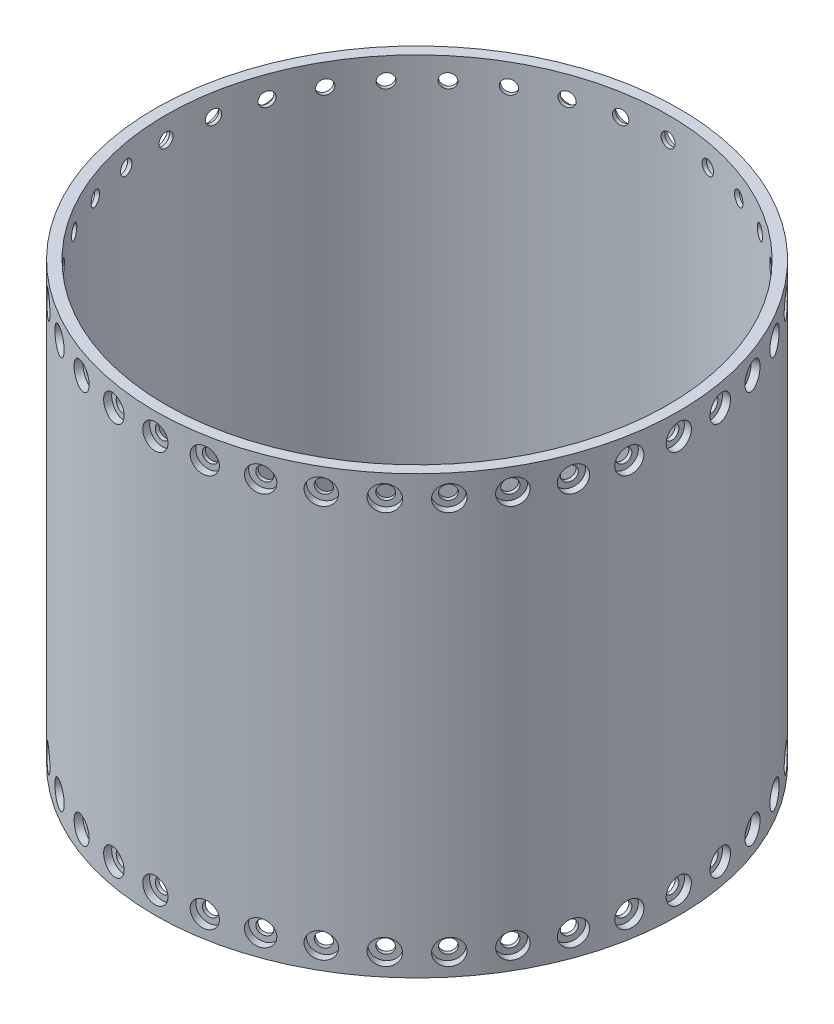
from build123d import *

# Parameters (mm, degrees)
SKETCH1_R           = 152.4
SKETCH1_R_2         = 146.05
BOSS_EXTRUDE1_DEPTH = 254
CIRPATTERN1_COUNT   = 36


with BuildPart() as part:
    # Sketch1 → Boss-Extrude1 (new body)
    with BuildSketch(Plane(origin=(0, 0, 0), x_dir=(1, 0, 0), z_dir=(0, 1, 0))):
        Circle(SKETCH1_R)
        Circle(SKETCH1_R_2, mode=Mode.SUBTRACT)
    extrude(amount=BOSS_EXTRUDE1_DEPTH)

    # Sketch4 → CBORE for 5/16 Button Head Cap Screw1 (revolve, cut)
    with BuildSketch(Plane(origin=(-152.4, 241.3, 0), x_dir=(0, 0, 1), z_dir=(0, 1, 0))):
        Polygon((0, 0), (0, 121.082790345), (4.1021, 118.618), (4.1021, 4.2164), (7.34187, 4.2164), (7.34187, 0), align=None)
    cbore_for_5_16_button_head_cap_screw1 = revolve(axis=Axis((-158.75, 241.3, 0), (1, 0, 0)), mode=Mode.SUBTRACT)

    # CirPattern1: CBORE for 5/16 Button Head Cap Screw1 ×36 about axis
    cirpattern1_axis = Axis((0, 0, 0), (0, 1, 0))
    for i in range(1, CIRPATTERN1_COUNT):
        add(cbore_for_5_16_button_head_cap_screw1.rotate(cirpattern1_axis, i * 360 / CIRPATTERN1_COUNT), mode=Mode.SUBTRACT)

    # Mirror1: CBORE for 5/16 Button Head Cap Screw1 across plane
    add(cbore_for_5_16_button_head_cap_screw1.mirror(Plane.ZX.offset(127)), mode=Mode.SUBTRACT)

    # Mirror1 copy 1 sketch → Mirror1 copy 1 (revolve, cut)
    with BuildSketch(Plane(origin=(-150.084701559, 12.7, 26.463982276), x_dir=(0.173648178, 0, 0.984807753), z_dir=(0, -1, 0))):
        Polygon((0, 0), (0, -121.082790345), (4.1021, -118.618), (4.1021, -4.2164), (7.34187, -4.2164), (7.34187, 0), align=None)
    revolve(axis=Axis((-156.338230791, 12.7, 27.566648205), (-0.984807753, 0, 0.173648178)), mode=Mode.SUBTRACT)

    # Mirror1 copy 2 sketch → Mirror1 copy 2 (revolve, cut)
    with BuildSketch(Plane(origin=(-143.209155408, 12.7, 52.123869843), x_dir=(0.342020143, 0, 0.939692621), z_dir=(0, -1, 0))):
        Polygon((0, 0), (0, -121.082790345), (4.1021, -118.618), (4.1021, -4.2164), (7.34187, -4.2164), (7.34187, 0), align=None)
    revolve(axis=Axis((-149.17620355, 12.7, 54.295697753), (-0.939692621, 0, 0.342020143)), mode=Mode.SUBTRACT)

    # Mirror1 copy 3 sketch → Mirror1 copy 3 (revolve, cut)
    with BuildSketch(Plane(origin=(-131.982271537, 12.7, 76.2), x_dir=(0.5, 0, 0.866025404), z_dir=(0, -1, 0))):
        Polygon((0, 0), (0, -121.082790345), (4.1021, -118.618), (4.1021, -4.2164), (7.34187, -4.2164), (7.34187, 0), align=None)
    revolve(axis=Axis((-137.481532851, 12.7, 79.375), (-0.866025404, 0, 0.5)), mode=Mode.SUBTRACT)

    # Mirror1 copy 4 sketch → Mirror1 copy 4 (revolve, cut)
    with BuildSketch(Plane(origin=(-116.745173131, 12.7, 97.960831716), x_dir=(0.64278761, 0, 0.766044443), z_dir=(0, -1, 0))):
        Polygon((0, 0), (0, -121.082790345), (4.1021, -118.618), (4.1021, -4.2164), (7.34187, -4.2164), (7.34187, 0), align=None)
    revolve(axis=Axis((-121.609555345, 12.7, 102.042533038), (-0.766044443, 0, 0.64278761)), mode=Mode.SUBTRACT)

    # Mirror1 copy 5 sketch → Mirror1 copy 5 (revolve, cut)
    with BuildSketch(Plane(origin=(-97.960831716, 12.7, 116.745173131), x_dir=(0.766044443, 0, 0.64278761), z_dir=(0, -1, 0))):
        Polygon((0, 0), (0, -121.082790345), (4.1021, -118.618), (4.1021, -4.2164), (7.34187, -4.2164), (7.34187, 0), align=None)
    revolve(axis=Axis((-102.042533038, 12.7, 121.609555345), (-0.64278761, 0, 0.766044443)), mode=Mode.SUBTRACT)

    # Mirror1 copy 6 sketch → Mirror1 copy 6 (revolve, cut)
    with BuildSketch(Plane(origin=(-76.2, 12.7, 131.982271537), x_dir=(0.866025404, 0, 0.5), z_dir=(0, -1, 0))):
        Polygon((0, 0), (0, -121.082790345), (4.1021, -118.618), (4.1021, -4.2164), (7.34187, -4.2164), (7.34187, 0), align=None)
    revolve(axis=Axis((-79.375, 12.7, 137.481532851), (-0.5, 0, 0.866025404)), mode=Mode.SUBTRACT)

    # Mirror1 copy 7 sketch → Mirror1 copy 7 (revolve, cut)
    with BuildSketch(Plane(origin=(-52.123869843, 12.7, 143.209155408), x_dir=(0.939692621, 0, 0.342020143), z_dir=(0, -1, 0))):
        Polygon((0, 0), (0, -121.082790345), (4.1021, -118.618), (4.1021, -4.2164), (7.34187, -4.2164), (7.34187, 0), align=None)
    revolve(axis=Axis((-54.295697753, 12.7, 149.17620355), (-0.342020143, 0, 0.939692621)), mode=Mode.SUBTRACT)

    # Mirror1 copy 8 sketch → Mirror1 copy 8 (revolve, cut)
    with BuildSketch(Plane(origin=(-26.463982276, 12.7, 150.084701559), x_dir=(0.984807753, 0, 0.173648178), z_dir=(0, -1, 0))):
        Polygon((0, 0), (0, -121.082790345), (4.1021, -118.618), (4.1021, -4.2164), (7.34187, -4.2164), (7.34187, 0), align=None)
    revolve(axis=Axis((-27.566648205, 12.7, 156.338230791), (-0.173648178, 0, 0.984807753)), mode=Mode.SUBTRACT)

    # Mirror1 copy 9 sketch → Mirror1 copy 9 (revolve, cut)
    with BuildSketch(Plane(origin=(0, 12.7, 152.4), x_dir=(1, 0, 0), z_dir=(0, -1, 0))):
        Polygon((0, 0), (0, -121.082790345), (4.1021, -118.618), (4.1021, -4.2164), (7.34187, -4.2164), (7.34187, 0), align=None)
    revolve(axis=Axis((0, 12.7, 158.75), (0, 0, 1)), mode=Mode.SUBTRACT)

    # Mirror1 copy 10 sketch → Mirror1 copy 10 (revolve, cut)
    with BuildSketch(Plane(origin=(26.463982276, 12.7, 150.084701559), x_dir=(0.984807753, 0, -0.173648178), z_dir=(0, -1, 0))):
        Polygon((0, 0), (0, -121.082790345), (4.1021, -118.618), (4.1021, -4.2164), (7.34187, -4.2164), (7.34187, 0), align=None)
    revolve(axis=Axis((27.566648205, 12.7, 156.338230791), (0.173648178, 0, 0.984807753)), mode=Mode.SUBTRACT)

    # Mirror1 copy 11 sketch → Mirror1 copy 11 (revolve, cut)
    with BuildSketch(Plane(origin=(52.123869843, 12.7, 143.209155408), x_dir=(0.939692621, 0, -0.342020143), z_dir=(0, -1, 0))):
        Polygon((0, 0), (0, -121.082790345), (4.1021, -118.618), (4.1021, -4.2164), (7.34187, -4.2164), (7.34187, 0), align=None)
    revolve(axis=Axis((54.295697753, 12.7, 149.17620355), (0.342020143, 0, 0.939692621)), mode=Mode.SUBTRACT)

    # Mirror1 copy 12 sketch → Mirror1 copy 12 (revolve, cut)
    with BuildSketch(Plane(origin=(76.2, 12.7, 131.982271537), x_dir=(0.866025404, 0, -0.5), z_dir=(0, -1, 0))):
        Polygon((0, 0), (0, -121.082790345), (4.1021, -118.618), (4.1021, -4.2164), (7.34187, -4.2164), (7.34187, 0), align=None)
    revolve(axis=Axis((79.375, 12.7, 137.481532851), (0.5, 0, 0.866025404)), mode=Mode.SUBTRACT)

    # Mirror1 copy 13 sketch → Mirror1 copy 13 (revolve, cut)
    with BuildSketch(Plane(origin=(97.960831716, 12.7, 116.745173131), x_dir=(0.766044443, 0, -0.64278761), z_dir=(0, -1, 0))):
        Polygon((0, 0), (0, -121.082790345), (4.1021, -118.618), (4.1021, -4.2164), (7.34187, -4.2164), (7.34187, 0), align=None)
    revolve(axis=Axis((102.042533038, 12.7, 121.609555345), (0.64278761, 0, 0.766044443)), mode=Mode.SUBTRACT)

    # Mirror1 copy 14 sketch → Mirror1 copy 14 (revolve, cut)
    with BuildSketch(Plane(origin=(116.745173131, 12.7, 97.960831716), x_dir=(0.64278761, 0, -0.766044443), z_dir=(0, -1, 0))):
        Polygon((0, 0), (0, -121.082790345), (4.1021, -118.618), (4.1021, -4.2164), (7.34187, -4.2164), (7.34187, 0), align=None)
    revolve(axis=Axis((121.609555345, 12.7, 102.042533038), (0.766044443, 0, 0.64278761)), mode=Mode.SUBTRACT)

    # Mirror1 copy 15 sketch → Mirror1 copy 15 (revolve, cut)
    with BuildSketch(Plane(origin=(131.982271537, 12.7, 76.2), x_dir=(0.5, 0, -0.866025404), z_dir=(0, -1, 0))):
        Polygon((0, 0), (0, -121.082790345), (4.1021, -118.618), (4.1021, -4.2164), (7.34187, -4.2164), (7.34187, 0), align=None)
    revolve(axis=Axis((137.481532851, 12.7, 79.375), (0.866025404, 0, 0.5)), mode=Mode.SUBTRACT)

    # Mirror1 copy 16 sketch → Mirror1 copy 16 (revolve, cut)
    with BuildSketch(Plane(origin=(143.209155408, 12.7, 52.123869843), x_dir=(0.342020143, 0, -0.939692621), z_dir=(0, -1, 0))):
        Polygon((0, 0), (0, -121.082790345), (4.1021, -118.618), (4.1021, -4.2164), (7.34187, -4.2164), (7.34187, 0), align=None)
    revolve(axis=Axis((149.17620355, 12.7, 54.295697753), (0.939692621, 0, 0.342020143)), mode=Mode.SUBTRACT)

    # Mirror1 copy 17 sketch → Mirror1 copy 17 (revolve, cut)
    with BuildSketch(Plane(origin=(150.084701559, 12.7, 26.463982276), x_dir=(0.173648178, 0, -0.984807753), z_dir=(0, -1, 0))):
        Polygon((0, 0), (0, -121.082790345), (4.1021, -118.618), (4.1021, -4.2164), (7.34187, -4.2164), (7.34187, 0), align=None)
    revolve(axis=Axis((156.338230791, 12.7, 27.566648205), (0.984807753, 0, 0.173648178)), mode=Mode.SUBTRACT)

    # Mirror1 copy 18 sketch → Mirror1 copy 18 (revolve, cut)
    with BuildSketch(Plane(origin=(152.4, 12.7, 0), x_dir=(0, 0, -1), z_dir=(0, -1, 0))):
        Polygon((0, 0), (0, -121.082790345), (4.1021, -118.618), (4.1021, -4.2164), (7.34187, -4.2164), (7.34187, 0), align=None)
    revolve(axis=Axis((158.75, 12.7, 0), (1, 0, 0)), mode=Mode.SUBTRACT)

    # Mirror1 copy 19 sketch → Mirror1 copy 19 (revolve, cut)
    with BuildSketch(Plane(origin=(150.084701559, 12.7, -26.463982276), x_dir=(-0.173648178, 0, -0.984807753), z_dir=(0, -1, 0))):
        Polygon((0, 0), (0, -121.082790345), (4.1021, -118.618), (4.1021, -4.2164), (7.34187, -4.2164), (7.34187, 0), align=None)
    revolve(axis=Axis((156.338230791, 12.7, -27.566648205), (0.984807753, 0, -0.173648178)), mode=Mode.SUBTRACT)

    # Mirror1 copy 20 sketch → Mirror1 copy 20 (revolve, cut)
    with BuildSketch(Plane(origin=(143.209155408, 12.7, -52.123869843), x_dir=(-0.342020143, 0, -0.939692621), z_dir=(0, -1, 0))):
        Polygon((0, 0), (0, -121.082790345), (4.1021, -118.618), (4.1021, -4.2164), (7.34187, -4.2164), (7.34187, 0), align=None)
    revolve(axis=Axis((149.17620355, 12.7, -54.295697753), (0.939692621, 0, -0.342020143)), mode=Mode.SUBTRACT)

    # Mirror1 copy 21 sketch → Mirror1 copy 21 (revolve, cut)
    with BuildSketch(Plane(origin=(131.982271537, 12.7, -76.2), x_dir=(-0.5, 0, -0.866025404), z_dir=(0, -1, 0))):
        Polygon((0, 0), (0, -121.082790345), (4.1021, -118.618), (4.1021, -4.2164), (7.34187, -4.2164), (7.34187, 0), align=None)
    revolve(axis=Axis((137.481532851, 12.7, -79.375), (0.866025404, 0, -0.5)), mode=Mode.SUBTRACT)

    # Mirror1 copy 22 sketch → Mirror1 copy 22 (revolve, cut)
    with BuildSketch(Plane(origin=(116.745173131, 12.7, -97.960831716), x_dir=(-0.64278761, 0, -0.766044443), z_dir=(0, -1, 0))):
        Polygon((0, 0), (0, -121.082790345), (4.1021, -118.618), (4.1021, -4.2164), (7.34187, -4.2164), (7.34187, 0), align=None)
    revolve(axis=Axis((121.609555345, 12.7, -102.042533038), (0.766044443, 0, -0.64278761)), mode=Mode.SUBTRACT)

    # Mirror1 copy 23 sketch → Mirror1 copy 23 (revolve, cut)
    with BuildSketch(Plane(origin=(97.960831716, 12.7, -116.745173131), x_dir=(-0.766044443, 0, -0.64278761), z_dir=(0, -1, 0))):
        Polygon((0, 0), (0, -121.082790345), (4.1021, -118.618), (4.1021, -4.2164), (7.34187, -4.2164), (7.34187, 0), align=None)
    revolve(axis=Axis((102.042533038, 12.7, -121.609555345), (0.64278761, 0, -0.766044443)), mode=Mode.SUBTRACT)

    # Mirror1 copy 24 sketch → Mirror1 copy 24 (revolve, cut)
    with BuildSketch(Plane(origin=(76.2, 12.7, -131.982271537), x_dir=(-0.866025404, 0, -0.5), z_dir=(0, -1, 0))):
        Polygon((0, 0), (0, -121.082790345), (4.1021, -118.618), (4.1021, -4.2164), (7.34187, -4.2164), (7.34187, 0), align=None)
    revolve(axis=Axis((79.375, 12.7, -137.481532851), (0.5, 0, -0.866025404)), mode=Mode.SUBTRACT)

    # Mirror1 copy 25 sketch → Mirror1 copy 25 (revolve, cut)
    with BuildSketch(Plane(origin=(52.123869843, 12.7, -143.209155408), x_dir=(-0.939692621, 0, -0.342020143), z_dir=(0, -1, 0))):
        Polygon((0, 0), (0, -121.082790345), (4.1021, -118.618), (4.1021, -4.2164), (7.34187, -4.2164), (7.34187, 0), align=None)
    revolve(axis=Axis((54.295697753, 12.7, -149.17620355), (0.342020143, 0, -0.939692621)), mode=Mode.SUBTRACT)

    # Mirror1 copy 26 sketch → Mirror1 copy 26 (revolve, cut)
    with BuildSketch(Plane(origin=(26.463982276, 12.7, -150.084701559), x_dir=(-0.984807753, 0, -0.173648178), z_dir=(0, -1, 0))):
        Polygon((0, 0), (0, -121.082790345), (4.1021, -118.618), (4.1021, -4.2164), (7.34187, -4.2164), (7.34187, 0), align=None)
    revolve(axis=Axis((27.566648205, 12.7, -156.338230791), (0.173648178, 0, -0.984807753)), mode=Mode.SUBTRACT)

    # Mirror1 copy 27 sketch → Mirror1 copy 27 (revolve, cut)
    with BuildSketch(Plane(origin=(0, 12.7, -152.4), x_dir=(-1, 0, 0), z_dir=(0, -1, 0))):
        Polygon((0, 0), (0, -121.082790345), (4.1021, -118.618), (4.1021, -4.2164), (7.34187, -4.2164), (7.34187, 0), align=None)
    revolve(axis=Axis((0, 12.7, -158.75), (0, 0, -1)), mode=Mode.SUBTRACT)

    # Mirror1 copy 28 sketch → Mirror1 copy 28 (revolve, cut)
    with BuildSketch(Plane(origin=(-26.463982276, 12.7, -150.084701559), x_dir=(-0.984807753, 0, 0.173648178), z_dir=(0, -1, 0))):
        Polygon((0, 0), (0, -121.082790345), (4.1021, -118.618), (4.1021, -4.2164), (7.34187, -4.2164), (7.34187, 0), align=None)
    revolve(axis=Axis((-27.566648205, 12.7, -156.338230791), (-0.173648178, 0, -0.984807753)), mode=Mode.SUBTRACT)

    # Mirror1 copy 29 sketch → Mirror1 copy 29 (revolve, cut)
    with BuildSketch(Plane(origin=(-52.123869843, 12.7, -143.209155408), x_dir=(-0.939692621, 0, 0.342020143), z_dir=(0, -1, 0))):
        Polygon((0, 0), (0, -121.082790345), (4.1021, -118.618), (4.1021, -4.2164), (7.34187, -4.2164), (7.34187, 0), align=None)
    revolve(axis=Axis((-54.295697753, 12.7, -149.17620355), (-0.342020143, 0, -0.939692621)), mode=Mode.SUBTRACT)

    # Mirror1 copy 30 sketch → Mirror1 copy 30 (revolve, cut)
    with BuildSketch(Plane(origin=(-76.2, 12.7, -131.982271537), x_dir=(-0.866025404, 0, 0.5), z_dir=(0, -1, 0))):
        Polygon((0, 0), (0, -121.082790345), (4.1021, -118.618), (4.1021, -4.2164), (7.34187, -4.2164), (7.34187, 0), align=None)
    revolve(axis=Axis((-79.375, 12.7, -137.481532851), (-0.5, 0, -0.866025404)), mode=Mode.SUBTRACT)

    # Mirror1 copy 31 sketch → Mirror1 copy 31 (revolve, cut)
    with BuildSketch(Plane(origin=(-97.960831716, 12.7, -116.745173131), x_dir=(-0.766044443, 0, 0.64278761), z_dir=(0, -1, 0))):
        Polygon((0, 0), (0, -121.082790345), (4.1021, -118.618), (4.1021, -4.2164), (7.34187, -4.2164), (7.34187, 0), align=None)
    revolve(axis=Axis((-102.042533038, 12.7, -121.609555345), (-0.64278761, 0, -0.766044443)), mode=Mode.SUBTRACT)

    # Mirror1 copy 32 sketch → Mirror1 copy 32 (revolve, cut)
    with BuildSketch(Plane(origin=(-116.745173131, 12.7, -97.960831716), x_dir=(-0.64278761, 0, 0.766044443), z_dir=(0, -1, 0))):
        Polygon((0, 0), (0, -121.082790345), (4.1021, -118.618), (4.1021, -4.2164), (7.34187, -4.2164), (7.34187, 0), align=None)
    revolve(axis=Axis((-121.609555345, 12.7, -102.042533038), (-0.766044443, 0, -0.64278761)), mode=Mode.SUBTRACT)

    # Mirror1 copy 33 sketch → Mirror1 copy 33 (revolve, cut)
    with BuildSketch(Plane(origin=(-131.982271537, 12.7, -76.2), x_dir=(-0.5, 0, 0.866025404), z_dir=(0, -1, 0))):
        Polygon((0, 0), (0, -121.082790345), (4.1021, -118.618), (4.1021, -4.2164), (7.34187, -4.2164), (7.34187, 0), align=None)
    revolve(axis=Axis((-137.481532851, 12.7, -79.375), (-0.866025404, 0, -0.5)), mode=Mode.SUBTRACT)

    # Mirror1 copy 34 sketch → Mirror1 copy 34 (revolve, cut)
    with BuildSketch(Plane(origin=(-143.209155408, 12.7, -52.123869843), x_dir=(-0.342020143, 0, 0.939692621), z_dir=(0, -1, 0))):
        Polygon((0, 0), (0, -121.082790345), (4.1021, -118.618), (4.1021, -4.2164), (7.34187, -4.2164), (7.34187, 0), align=None)
    revolve(axis=Axis((-149.17620355, 12.7, -54.295697753), (-0.939692621, 0, -0.342020143)), mode=Mode.SUBTRACT)

    # Mirror1 copy 35 sketch → Mirror1 copy 35 (revolve, cut)
    with BuildSketch(Plane(origin=(-150.084701559, 12.7, -26.463982276), x_dir=(-0.173648178, 0, 0.984807753), z_dir=(0, -1, 0))):
        Polygon((0, 0), (0, -121.082790345), (4.1021, -118.618), (4.1021, -4.2164), (7.34187, -4.2164), (7.34187, 0), align=None)
    revolve(axis=Axis((-156.338230791, 12.7, -27.566648205), (-0.984807753, 0, -0.173648178)), mode=Mode.SUBTRACT)


solid = part.part
